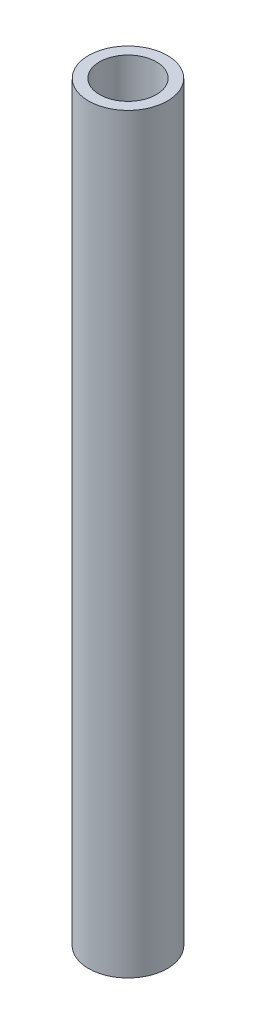
from build123d import *

# Parameters (mm, degrees)
SKETCH1_R           = 3.175
SKETCH1_R_2         = 2.286
BOSS_EXTRUDE1_DEPTH = 60.480702


with BuildPart() as part:
    # Sketch1 → Boss-Extrude1 (new body)
    with BuildSketch(Plane(origin=(0, 0, 0), x_dir=(1, 0, 0), z_dir=(0, 1, 0))):
        Circle(SKETCH1_R)
        Circle(SKETCH1_R_2, mode=Mode.SUBTRACT)
    extrude(amount=BOSS_EXTRUDE1_DEPTH)


solid = part.part
